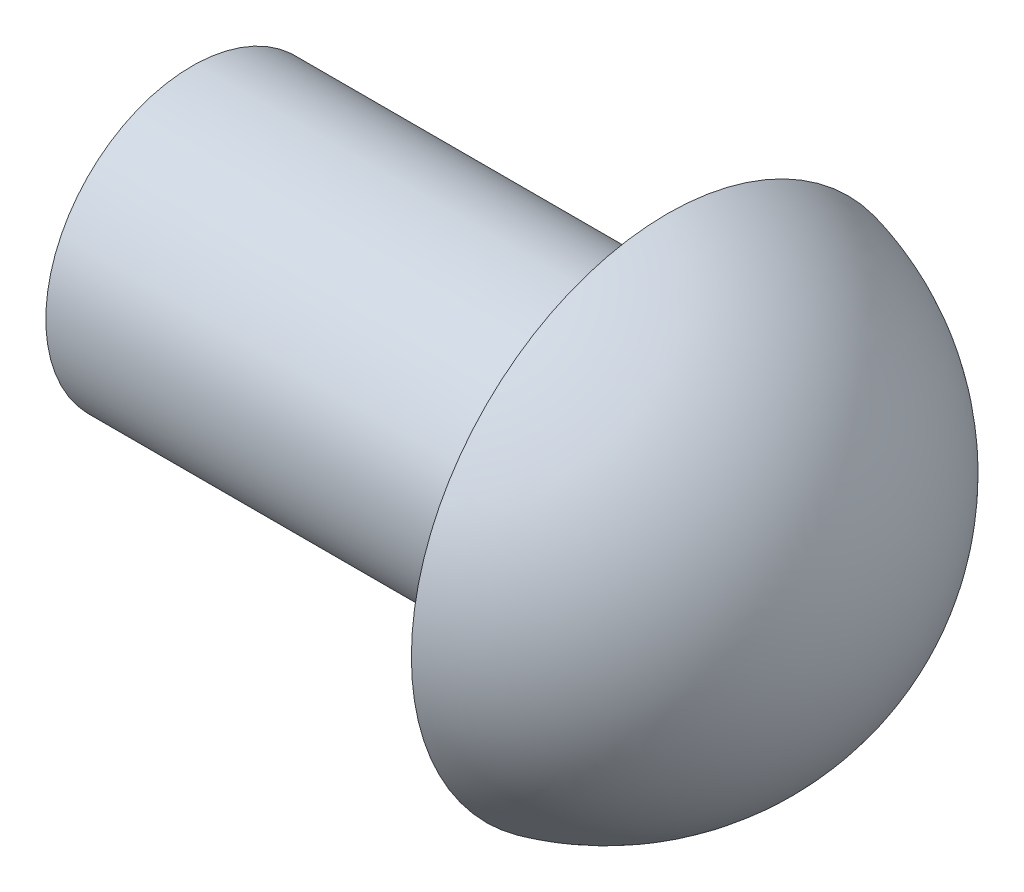
from build123d import *

# Parameters (mm, degrees)
SKETCH1_R           = 2
BOSS_EXTRUDE1_DEPTH = 6.5


with BuildPart() as part:
    # Sketch1 → Boss-Extrude1 (new body)
    with BuildSketch(Plane(origin=(0, 0, 0), x_dir=(0, 0, -1), z_dir=(1, 0, 0))):
        Circle(SKETCH1_R)
    extrude(amount=BOSS_EXTRUDE1_DEPTH)

    # Sketch2 → Revolve1 (revolve)
    with BuildSketch(Plane(origin=(0, 0, 0), x_dir=(1, 0, 0), z_dir=(0, 1, 0))):
        with BuildLine():
            Line((9.260092934, 0), (6.5, 0))
            Line((6.5, 0), (6.5, 3.5))
            ThreePointArc((6.5, 3.5), (8.486874454, 2.228543325), (9.260092934, 0))
        make_face()
    revolve(axis=Axis((3.571865943, 0, 0), (1, 0, 0)))


solid = part.part
